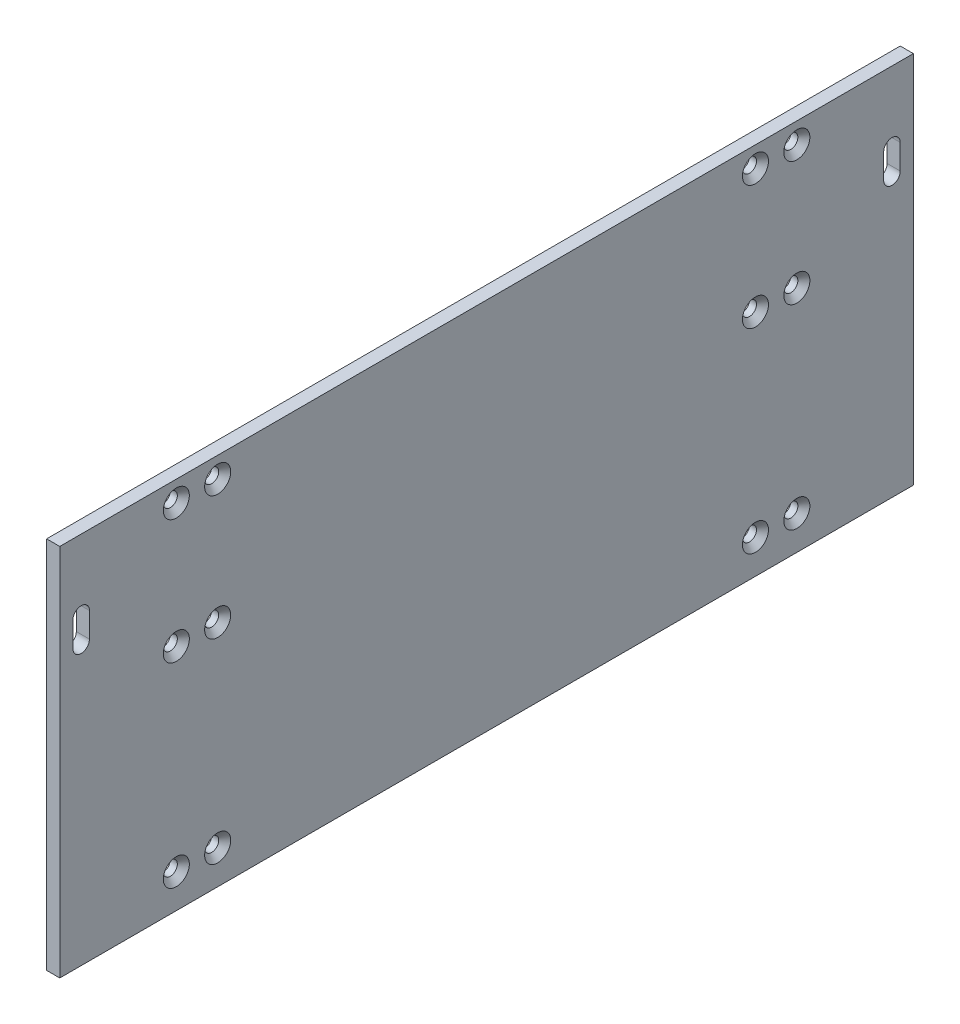
from build123d import *

# Parameters (mm, degrees)
BOSS_EXTRUDE1_DEPTH                             = 3.175
CSK_FOR_M3_FLAT_HEAD_MACHINE_SCREW1_D           = 3.4
CSK_FOR_M3_FLAT_HEAD_MACHINE_SCREW1_CSINK_D     = 6.3
CSK_FOR_M3_FLAT_HEAD_MACHINE_SCREW1_CSINK_ANGLE = 90
CUT_EXTRUDE1_DEPTH                              = 4.175


with BuildPart() as part:
    # Sketch1 → Boss-Extrude1 (new body)
    with BuildSketch(Plane(origin=(0, 0, 0), x_dir=(0, 0, -1), z_dir=(1, 0, 0))):
        Polygon((103.175, 0), (103.175, 3.175), (103.175, 47.175), (103.175, 50.35), (103.175, 60.35), (103.175, 90.35), (-103.175, 90.35), (-103.175, 60.35), (-103.175, 50.35), (-103.175, 47.175), (-103.175, 3.175), (-103.175, 0), align=None)
    extrude(amount=BOSS_EXTRUDE1_DEPTH)

    # CSK for M3 Flat Head Machine Screw1 (through all)
    with Locations(Plane(origin=(3.175, 0, 0), x_dir=(0, 0, -1), z_dir=(1, 0, 0))):
        with Locations((-75, 8.175), (-65, 8.175), (-75, 55.35), (-65, 55.35), (-75, 85.35), (-65, 85.35)):
            csk_for_m3_flat_head_machine_screw1 = CounterSinkHole(CSK_FOR_M3_FLAT_HEAD_MACHINE_SCREW1_D / 2, CSK_FOR_M3_FLAT_HEAD_MACHINE_SCREW1_CSINK_D / 2, counter_sink_angle=CSK_FOR_M3_FLAT_HEAD_MACHINE_SCREW1_CSINK_ANGLE)

    # Mirror1: CSK for M3 Flat Head Machine Screw1 across plane
    add(csk_for_m3_flat_head_machine_screw1.mirror(Plane.XY), mode=Mode.SUBTRACT)

    # Sketch4 → Cut-Extrude1 (cut, through all)
    with BuildSketch(Plane(origin=(3.175, 0, 0), x_dir=(0, 0, -1), z_dir=(1, 0, 0))):
        with BuildLine():
            Line((-96, 73.35), (-96, 67.35))
            ThreePointArc((-96, 67.35), (-98, 65.35), (-100, 67.35))
            Line((-100, 67.35), (-100, 73.35))
            ThreePointArc((-100, 73.35), (-98, 75.35), (-96, 73.35))
        make_face()
        with BuildLine():
            Line((96, 73.35), (96, 67.35))
            ThreePointArc((96, 67.35), (98, 65.35), (100, 67.35))
            Line((100, 67.35), (100, 73.35))
            ThreePointArc((100, 73.35), (98, 75.35), (96, 73.35))
        make_face()
    extrude(amount=-CUT_EXTRUDE1_DEPTH, mode=Mode.SUBTRACT)


solid = part.part
